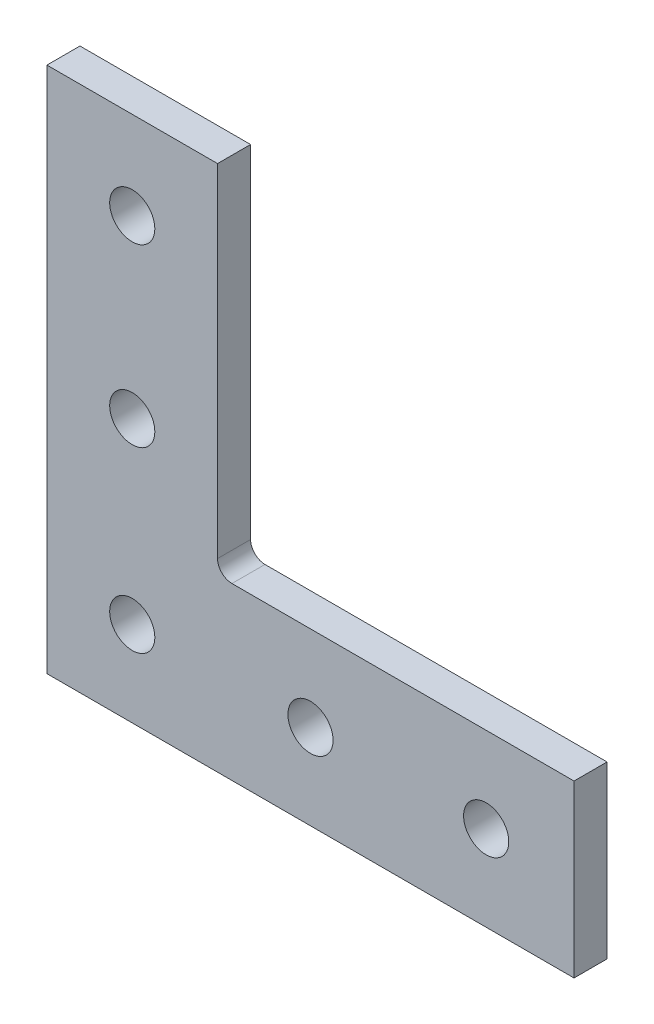
from build123d import *

# Parameters (mm, degrees)
BOSS_EXTRUDE1_DEPTH      = 2.3876
BOSS_EXTRUDE1_DEPTH_BACK = 2.3876
SKETCH4_R                = 3.2639
CUT_EXTRUDE1_DEPTH       = 1
CUT_EXTRUDE1_DEPTH_BACK  = 5.7752


with BuildPart() as part:
    # Sketch3 → Boss-Extrude1 (new body, two sides)
    with BuildSketch(Plane.XY) as boss_extrude1_sk:
        with BuildLine():
            Line((-13.4366, 38.1), (-38.1, 38.1))
            Line((-38.1, 38.1), (-38.1, -38.1))
            Line((-38.1, -38.1), (38.1, -38.1))
            Line((38.1, -38.1), (38.1, -13.4366))
            Line((38.1, -13.4366), (-11.3538, -13.4366))
            ThreePointArc((-11.3538, -13.4366), (-12.826562004, -12.826562004), (-13.4366, -11.3538))
            Line((-13.4366, -11.3538), (-13.4366, 38.1))
        make_face()
    extrude(amount=BOSS_EXTRUDE1_DEPTH)
    extrude(boss_extrude1_sk.sketch, amount=-BOSS_EXTRUDE1_DEPTH_BACK)

    # Sketch4 → Cut-Extrude1 (cut, two sides)
    with BuildSketch(Plane.XY.offset(2.3876)) as cut_extrude1_sk:
        with Locations((-25.7683, 25.4)):
            Circle(SKETCH4_R)
        with Locations((-25.7683, 0)):
            Circle(SKETCH4_R)
        with Locations((0, -25.7683)):
            Circle(SKETCH4_R)
        with Locations((25.4, -25.7683)):
            Circle(SKETCH4_R)
        with Locations((-25.7683, -25.7683)):
            Circle(SKETCH4_R)
    extrude(amount=CUT_EXTRUDE1_DEPTH, mode=Mode.SUBTRACT)
    extrude(cut_extrude1_sk.sketch, amount=-CUT_EXTRUDE1_DEPTH_BACK, mode=Mode.SUBTRACT)


solid = part.part
